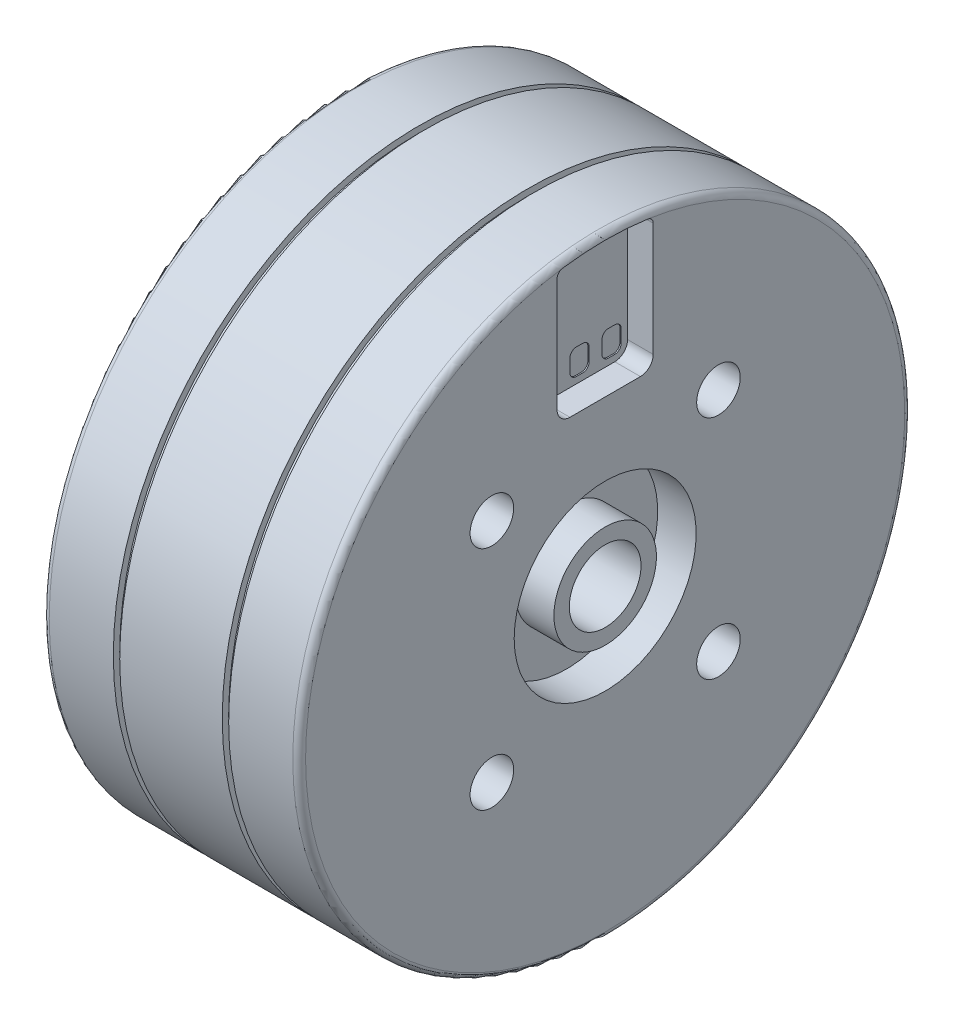
from build123d import *

# Parameters (mm, degrees)
R_P_TITION_CIRCULAIRE1_COUNT = 4
ENL_V_MAT_EXTRU_1_DEPTH      = 2.1
ENL_V_MAT_EXTRU_2_DEPTH      = 2


with BuildPart() as part:
    # Esquisse1 → Révolution1 (revolve)
    with BuildSketch(Plane.XY):
        with BuildLine():
            Line((0, 2.8), (0, 23.375))
            ThreePointArc((0, 23.375), (0.146446609, 23.728553391), (0.5, 23.875))
            Line((0.5, 23.875), (5.5, 23.875))
            Line((5.5, 23.875), (5.5, 23.375))
            Line((5.5, 23.375), (6, 23.375))
            Line((6, 23.375), (6, 23.875))
            Line((6, 23.875), (14, 23.875))
            Line((14, 23.875), (14, 23.375))
            Line((14, 23.375), (14.5, 23.375))
            Line((14.5, 23.375), (14.5, 23.875))
            Line((14.5, 23.875), (19.5, 23.875))
            ThreePointArc((19.5, 23.875), (19.853553391, 23.728553391), (20, 23.375))
            Line((20, 23.375), (20, 7.1))
            Line((20, 7.1), (17, 7.1))
            Line((17, 7.1), (17, 4))
            Line((17, 4), (20, 4))
            Line((20, 4), (20, 2.8))
            Line((20, 2.8), (0, 2.8))
        make_face()
    revolve(axis=Axis((-88.596801802, 0, 0), (1, 0, 0)))

    # Esquisse4 → Dégagement M2.51 (revolve, cut)
    with BuildSketch(Plane.ZX.offset(7.5)):
        Polygon((0, 0), (0, 3.371247898), (1.45, 2.5), (1.45, 0), align=None)
    d_gagement_m2_51 = revolve(axis=Axis((-6.35, 7.5, 0), (1, 0, 0)), mode=Mode.SUBTRACT)

    # Esquisse7 → Dégagement M31 (revolve, cut)
    with BuildSketch(Plane(origin=(20, 8.838834765, 8.838834765), x_dir=(0, 0, -1), z_dir=(0, 1, 0))):
        Polygon((0, 0), (0, 3.521463052), (1.7, 2.5), (1.7, 0), align=None)
    d_gagement_m31 = revolve(axis=Axis((26.35, 8.838834765, 8.838834765), (-1, 0, 0)), mode=Mode.SUBTRACT)

    # Répétition circulaire1: Dégagement M2.51, Dégagement M31 ×4 about axis
    r_p_tition_circulaire1_axis = Axis((0, 0, 0), (1, 0, 0))
    for i in range(1, R_P_TITION_CIRCULAIRE1_COUNT):
        add(d_gagement_m2_51.rotate(r_p_tition_circulaire1_axis, i * 360 / R_P_TITION_CIRCULAIRE1_COUNT), mode=Mode.SUBTRACT)
        add(d_gagement_m31.rotate(r_p_tition_circulaire1_axis, i * 360 / R_P_TITION_CIRCULAIRE1_COUNT), mode=Mode.SUBTRACT)

    # Esquisse9 → Enlèv. mat.-Extru.1 (cut)
    with BuildSketch(Plane(origin=(20, 0, 0), x_dir=(0, 0, -1), z_dir=(1, 0, 0))):
        with BuildLine():
            Line((2.75, 13.282856857), (2.25, 13.282856857))
            ThreePointArc((2.25, 13.282856857), (1.896446609, 13.429303466), (1.75, 13.782856857))
            Line((1.75, 13.782856857), (1.75, 14.782856857))
            ThreePointArc((1.75, 14.782856857), (1.896446609, 15.136410248), (2.25, 15.282856857))
            Line((2.25, 15.282856857), (2.75, 15.282856857))
            ThreePointArc((2.75, 15.282856857), (3.103553391, 15.136410248), (3.25, 14.782856857))
            Line((3.25, 14.782856857), (3.25, 13.782856857))
            ThreePointArc((3.25, 13.782856857), (3.103553391, 13.429303466), (2.75, 13.282856857))
        make_face()
        with BuildLine():
            Line((0.25, 13.282856857), (-0.25, 13.282856857))
            ThreePointArc((-0.25, 13.282856857), (-0.603553391, 13.429303466), (-0.75, 13.782856857))
            Line((-0.75, 13.782856857), (-0.75, 14.782856857))
            ThreePointArc((-0.75, 14.782856857), (-0.603553391, 15.136410248), (-0.25, 15.282856857))
            Line((-0.25, 15.282856857), (0.25, 15.282856857))
            ThreePointArc((0.25, 15.282856857), (0.603553391, 15.136410248), (0.75, 14.782856857))
            Line((0.75, 14.782856857), (0.75, 13.782856857))
            ThreePointArc((0.75, 13.782856857), (0.603553391, 13.429303466), (0.25, 13.282856857))
        make_face()
        with BuildLine():
            Line((-2.25, 13.282856857), (-2.75, 13.282856857))
            ThreePointArc((-2.75, 13.282856857), (-3.103553391, 13.429303466), (-3.25, 13.782856857))
            Line((-3.25, 13.782856857), (-3.25, 14.782856857))
            ThreePointArc((-3.25, 14.782856857), (-3.103553391, 15.136410248), (-2.75, 15.282856857))
            Line((-2.75, 15.282856857), (-2.25, 15.282856857))
            ThreePointArc((-2.25, 15.282856857), (-1.896446609, 15.136410248), (-1.75, 14.782856857))
            Line((-1.75, 14.782856857), (-1.75, 13.782856857))
            ThreePointArc((-1.75, 13.782856857), (-1.896446609, 13.429303466), (-2.25, 13.282856857))
        make_face()
    extrude(amount=-ENL_V_MAT_EXTRU_1_DEPTH, mode=Mode.SUBTRACT)

    # Esquisse10 → Enlèv. mat.-Extru.2 (cut)
    with BuildSketch(Plane(origin=(20, 0, 0), x_dir=(0, 0, -1), z_dir=(1, 0, 0))):
        with BuildLine():
            Line((3.75, 22.642948682), (3.75, 13.782856857))
            ThreePointArc((3.75, 13.782856857), (3.457106781, 13.075750076), (2.75, 12.782856857))
            Line((2.75, 12.782856857), (-2.75, 12.782856857))
            ThreePointArc((-2.75, 12.782856857), (-3.457106781, 13.075750076), (-3.75, 13.782856857))
            Line((-3.75, 13.782856857), (-3.75, 22.642948682))
            ThreePointArc((-3.75, 22.642948682), (-3.627835365, 22.970424539), (-3.321038251, 23.137876522))
            ThreePointArc((-3.321038251, 23.137876522), (0, 23.375), (3.321038251, 23.137876522))
            ThreePointArc((3.321038251, 23.137876522), (3.627835365, 22.970424539), (3.75, 22.642948682))
        make_face()
    extrude(amount=-ENL_V_MAT_EXTRU_2_DEPTH, mode=Mode.SUBTRACT)


solid = part.part
